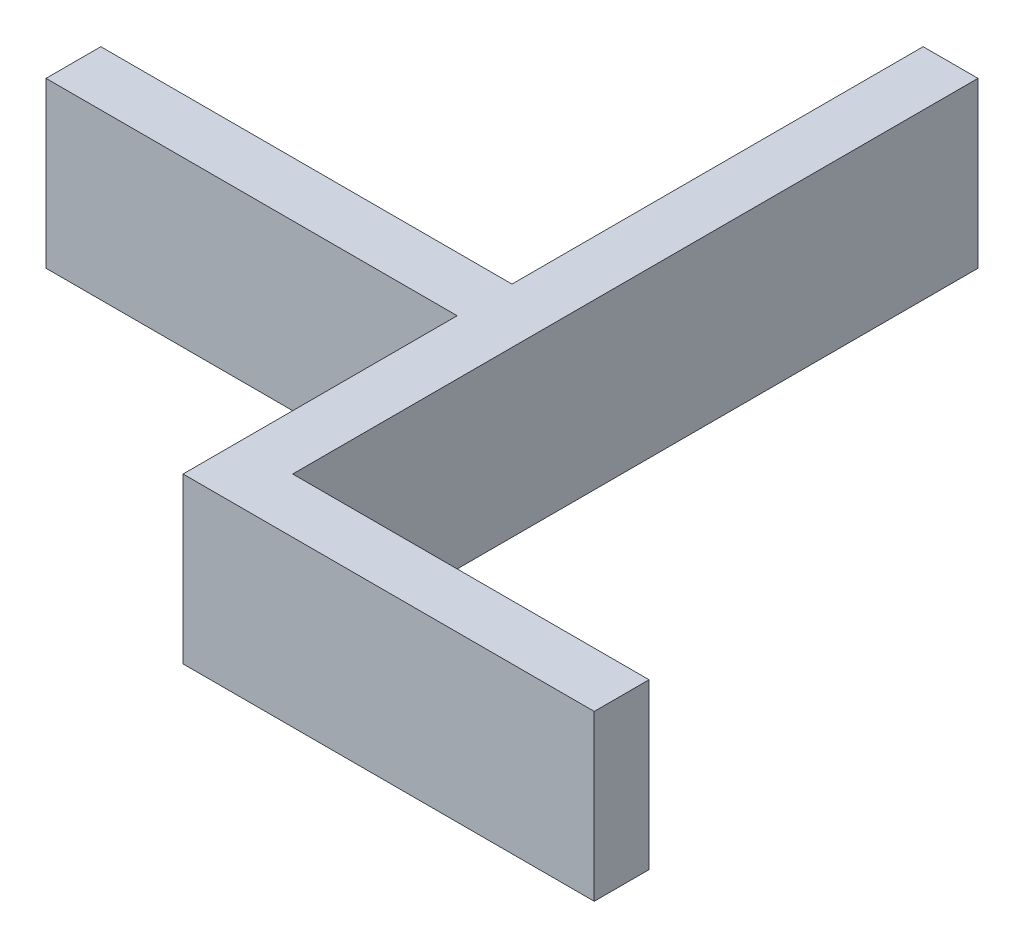
from build123d import *

# Parameters (mm, degrees)
ESQUISSE1_W        = 25
ESQUISSE1_H        = 6
BOSS_EXTRU_2_DEPTH = 2
ESQUISSE1_4_W      = 2
ESQUISSE1_4_H      = 6
BOSS_EXTRU_3_DEPTH = 15
ESQUISSE1_5_W      = 2
ESQUISSE1_5_H      = 6
BOSS_EXTRU_4_DEPTH = 15


with BuildPart() as part:
    # Esquisse1 → Boss.-Extru.2 (new body)
    with BuildSketch(Plane(origin=(0, 0, 0), x_dir=(0, 0, -1), z_dir=(1, 0, 0))):
        with Locations((-15.278399311, -28.757343568)):
            Rectangle(ESQUISSE1_W, ESQUISSE1_H)
    extrude(amount=BOSS_EXTRU_2_DEPTH)

    # Esquisse1_4 → Boss.-Extru.3 (add)
    with BuildSketch(Plane(origin=(0, 0, 0), x_dir=(0, 0, -1), z_dir=(1, 0, 0))):
        with Locations((-28.778399311, -28.757343568)):
            Rectangle(ESQUISSE1_4_W, ESQUISSE1_4_H)
    extrude(amount=BOSS_EXTRU_3_DEPTH)

    # Esquisse1_5 → Boss.-Extru.4 (add)
    with BuildSketch(Plane(origin=(0, 0, 0), x_dir=(0, 0, -1), z_dir=(1, 0, 0))):
        with Locations((-18.778399311, -28.757343568)):
            Rectangle(ESQUISSE1_5_W, ESQUISSE1_5_H)
    extrude(amount=-BOSS_EXTRU_4_DEPTH)


solid = part.part
